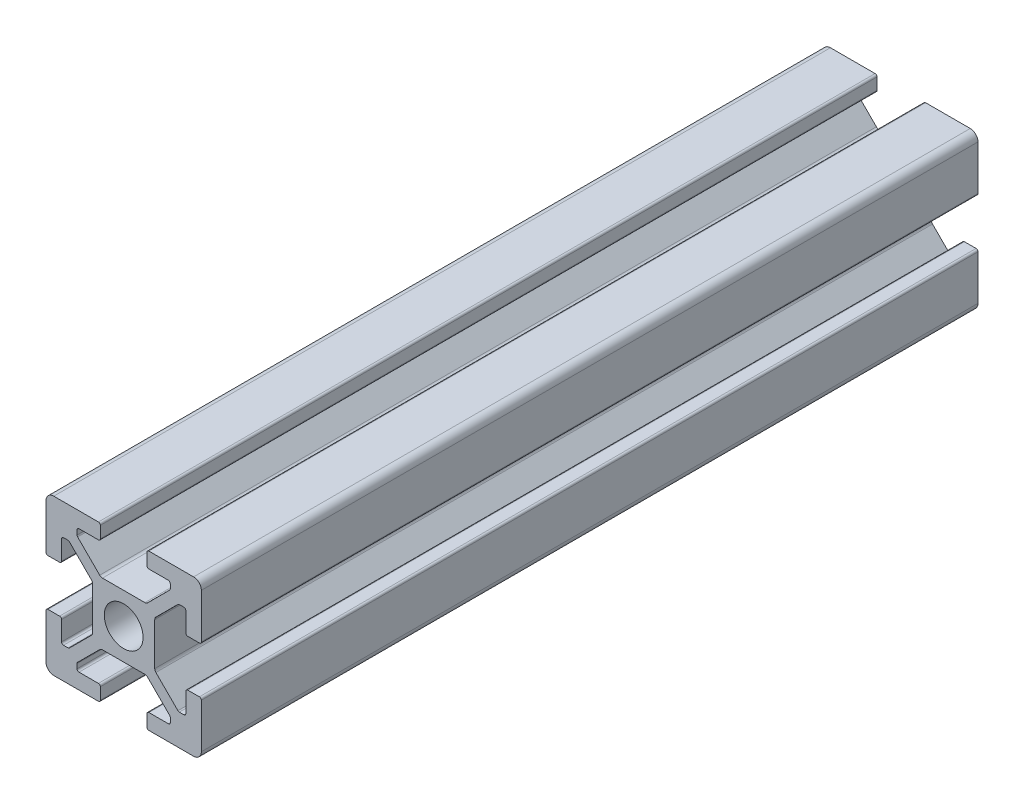
from build123d import *

# Parameters (mm, degrees)
SKETCH2_R           = 2.5
BOSS_EXTRUDE1_DEPTH = 100


with BuildPart() as part:
    # Sketch2 → Boss-Extrude1 (new body)
    with BuildSketch(Plane.XY):
        with BuildLine():
            Line((10, 3.25), (10, 9))
            ThreePointArc((10, 9), (9.707106781, 9.707106781), (9, 10))
            Line((9, 10), (3.25, 10))
            ThreePointArc((3.25, 10), (3.073223305, 9.926776695), (3, 9.75))
            Line((3, 9.75), (3, 8.25))
            ThreePointArc((3, 8.25), (3.073223305, 8.073223305), (3.25, 8))
            Line((3.25, 8), (5.75, 8))
            ThreePointArc((5.75, 8), (5.926776695, 7.926776695), (6, 7.75))
            Line((6, 7.75), (6, 7.164213562))
            ThreePointArc((6, 7.164213562), (5.980969883, 7.068542704), (5.926776695, 6.987436867))
            Line((5.926776695, 6.987436867), (3.085786438, 4.146446609))
            ThreePointArc((3.085786438, 4.146446609), (2.923574763, 4.038060234), (2.732233047, 4))
            Line((2.732233047, 4), (-2.732233047, 4))
            ThreePointArc((-2.732233047, 4), (-2.923574763, 4.038060234), (-3.085786438, 4.146446609))
            Line((-3.085786438, 4.146446609), (-5.926776695, 6.987436867))
            ThreePointArc((-5.926776695, 6.987436867), (-5.980969883, 7.068542704), (-6, 7.164213562))
            Line((-6, 7.164213562), (-6, 7.75))
            ThreePointArc((-6, 7.75), (-5.926776695, 7.926776695), (-5.75, 8))
            Line((-5.75, 8), (-3.25, 8))
            ThreePointArc((-3.25, 8), (-3.073223305, 8.073223305), (-3, 8.25))
            Line((-3, 8.25), (-3, 9.75))
            ThreePointArc((-3, 9.75), (-3.073223305, 9.926776695), (-3.25, 10))
            Line((-3.25, 10), (-9, 10))
            ThreePointArc((-9, 10), (-9.707106781, 9.707106781), (-10, 9))
            Line((-10, 9), (-10, 3.25))
            ThreePointArc((-10, 3.25), (-9.926776695, 3.073223305), (-9.75, 3))
            Line((-9.75, 3), (-8.25, 3))
            ThreePointArc((-8.25, 3), (-8.073223305, 3.073223305), (-8, 3.25))
            Line((-8, 3.25), (-8, 5.75))
            ThreePointArc((-8, 5.75), (-7.926776695, 5.926776695), (-7.75, 6))
            Line((-7.75, 6), (-7.164213562, 6))
            ThreePointArc((-7.164213562, 6), (-7.068542704, 5.980969883), (-6.987436867, 5.926776695))
            Line((-6.987436867, 5.926776695), (-4.146446609, 3.085786438))
            ThreePointArc((-4.146446609, 3.085786438), (-4.038060234, 2.923574763), (-4, 2.732233047))
            Line((-4, 2.732233047), (-4, -2.732233047))
            ThreePointArc((-4, -2.732233047), (-4.038060234, -2.923574763), (-4.146446609, -3.085786438))
            Line((-4.146446609, -3.085786438), (-6.987436867, -5.926776695))
            ThreePointArc((-6.987436867, -5.926776695), (-7.068542704, -5.980969883), (-7.164213562, -6))
            Line((-7.164213562, -6), (-7.75, -6))
            ThreePointArc((-7.75, -6), (-7.926776695, -5.926776695), (-8, -5.75))
            Line((-8, -5.75), (-8, -3.25))
            ThreePointArc((-8, -3.25), (-8.073223305, -3.073223305), (-8.25, -3))
            Line((-8.25, -3), (-9.75, -3))
            ThreePointArc((-9.75, -3), (-9.926776695, -3.073223305), (-10, -3.25))
            Line((-10, -3.25), (-10, -9))
            ThreePointArc((-10, -9), (-9.707106781, -9.707106781), (-9, -10))
            Line((-9, -10), (-3.25, -10))
            ThreePointArc((-3.25, -10), (-3.073223305, -9.926776695), (-3, -9.75))
            Line((-3, -9.75), (-3, -8.25))
            ThreePointArc((-3, -8.25), (-3.073223305, -8.073223305), (-3.25, -8))
            Line((-3.25, -8), (-5.75, -8))
            ThreePointArc((-5.75, -8), (-5.926776695, -7.926776695), (-6, -7.75))
            Line((-6, -7.75), (-6, -7.164213562))
            ThreePointArc((-6, -7.164213562), (-5.980969883, -7.068542704), (-5.926776695, -6.987436867))
            Line((-5.926776695, -6.987436867), (-3.085786438, -4.146446609))
            ThreePointArc((-3.085786438, -4.146446609), (-2.923574763, -4.038060234), (-2.732233047, -4))
            Line((-2.732233047, -4), (2.732233047, -4))
            ThreePointArc((2.732233047, -4), (2.923574763, -4.038060234), (3.085786438, -4.146446609))
            Line((3.085786438, -4.146446609), (5.926776695, -6.987436867))
            ThreePointArc((5.926776695, -6.987436867), (5.980969883, -7.068542704), (6, -7.164213562))
            Line((6, -7.164213562), (6, -7.75))
            ThreePointArc((6, -7.75), (5.926776695, -7.926776695), (5.75, -8))
            Line((5.75, -8), (3.25, -8))
            ThreePointArc((3.25, -8), (3.073223305, -8.073223305), (3, -8.25))
            Line((3, -8.25), (3, -9.75))
            ThreePointArc((3, -9.75), (3.073223305, -9.926776695), (3.25, -10))
            Line((3.25, -10), (9, -10))
            ThreePointArc((9, -10), (9.707106781, -9.707106781), (10, -9))
            Line((10, -9), (10, -3.25))
            ThreePointArc((10, -3.25), (9.926776695, -3.073223305), (9.75, -3))
            Line((9.75, -3), (8.25, -3))
            ThreePointArc((8.25, -3), (8.073223305, -3.073223305), (8, -3.25))
            Line((8, -3.25), (8, -5.75))
            ThreePointArc((8, -5.75), (7.926776695, -5.926776695), (7.75, -6))
            Line((7.75, -6), (7.164213562, -6))
            ThreePointArc((7.164213562, -6), (7.068542704, -5.980969883), (6.987436867, -5.926776695))
            Line((6.987436867, -5.926776695), (4.146446609, -3.085786438))
            ThreePointArc((4.146446609, -3.085786438), (4.038060234, -2.923574763), (4, -2.732233047))
            Line((4, -2.732233047), (4, 2.732233047))
            ThreePointArc((4, 2.732233047), (4.038060234, 2.923574763), (4.146446609, 3.085786438))
            Line((4.146446609, 3.085786438), (6.987436867, 5.926776695))
            ThreePointArc((6.987436867, 5.926776695), (7.068542704, 5.980969883), (7.164213562, 6))
            Line((7.164213562, 6), (7.75, 6))
            ThreePointArc((7.75, 6), (7.926776695, 5.926776695), (8, 5.75))
            Line((8, 5.75), (8, 3.25))
            ThreePointArc((8, 3.25), (8.073223305, 3.073223305), (8.25, 3))
            Line((8.25, 3), (9.75, 3))
            ThreePointArc((9.75, 3), (9.926776695, 3.073223305), (10, 3.25))
        make_face()
        Circle(SKETCH2_R, mode=Mode.SUBTRACT)
    extrude(amount=BOSS_EXTRUDE1_DEPTH)


solid = part.part
